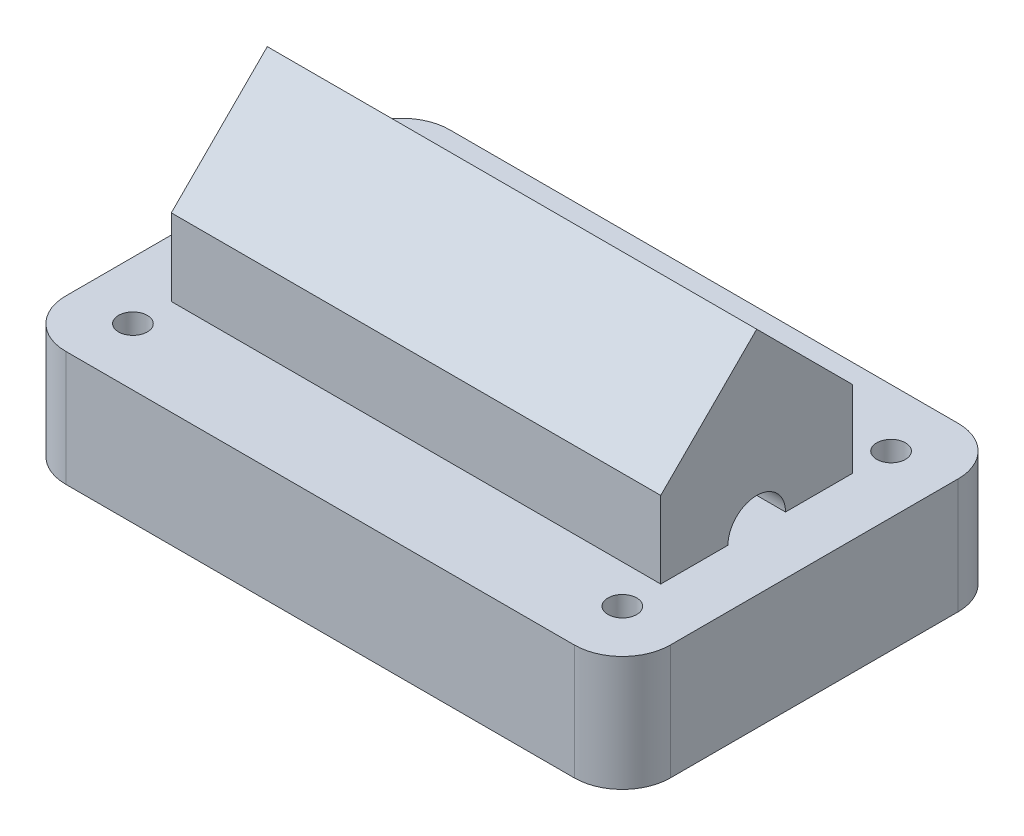
from build123d import *

# Parameters (mm, degrees)
IZIM1_W                     = 315
IZIM1_H                     = 200
Y_KSEKLIK_EKSTR_ZYON1_DEPTH = 60
RADYUS1_R                   = 25
IZIM2_R                     = 7.5
KES_EKSTR_ZYON1_DEPTH       = 61
IZIM3_W                     = 255
IZIM3_H                     = 100
Y_KSEKLIK_EKSTR_ZYON2_DEPTH = 40
Y_KSEKLIK_EKSTR_ZYON3_DEPTH = 255
KES_EKSTR_ZYON2_DEPTH       = 286


with BuildPart() as part:
    # Çizim1 → Yükseklik-Ekstrüzyon1 (new body)
    with BuildSketch(Plane(origin=(0, 0, 0), x_dir=(1, 0, 0), z_dir=(0, 1, 0))):
        Rectangle(IZIM1_W, IZIM1_H)
    extrude(amount=Y_KSEKLIK_EKSTR_ZYON1_DEPTH)

    # Radyus1
    radyus1_edges = [part.edges().sort_by_distance(p)[0] for p in [
        (157.5, 30, 100),
        (-157.5, 30, 100),
        (-157.5, 30, -100),
        (157.5, 30, -100),
    ]]
    fillet(radyus1_edges, radius=RADYUS1_R)

    # Çizim2 → Kes-Ekstrüzyon1 (cut, through all)
    with BuildSketch(Plane(origin=(0, 60, 0), x_dir=(1, 0, 0), z_dir=(0, 1, 0))):
        with Locations((-127.5, 70)):
            Circle(IZIM2_R)
        with Locations((127.5, 70)):
            Circle(IZIM2_R)
        with Locations((127.5, -70)):
            Circle(IZIM2_R)
        with Locations((-127.5, -70)):
            Circle(IZIM2_R)
    extrude(amount=-KES_EKSTR_ZYON1_DEPTH, mode=Mode.SUBTRACT)

    # Çizim3 → Yükseklik-Ekstrüzyon2 (add)
    with BuildSketch(Plane(origin=(0, 60, 0), x_dir=(1, 0, 0), z_dir=(0, 1, 0))):
        Rectangle(IZIM3_W, IZIM3_H)
    extrude(amount=Y_KSEKLIK_EKSTR_ZYON2_DEPTH)

    # Çizim4 → Yükseklik-Ekstrüzyon3 (add)
    with BuildSketch(Plane(origin=(127.5, 0, 0), x_dir=(0, 0, -1), z_dir=(1, 0, 0))):
        Polygon((-50, 100), (0, 150), (50, 100), align=None)
    extrude(amount=-Y_KSEKLIK_EKSTR_ZYON3_DEPTH)

    # Çizim5 → Kes-Ekstrüzyon2 (cut, through all)
    with BuildSketch(Plane(origin=(127.5, 0, 0), x_dir=(0, 0, -1), z_dir=(1, 0, 0))):
        with BuildLine():
            Line((-15, 60), (15, 60))
            ThreePointArc((15, 60), (0, 75), (-15, 60))
        make_face()
    extrude(amount=-KES_EKSTR_ZYON2_DEPTH, mode=Mode.SUBTRACT)


solid = part.part
